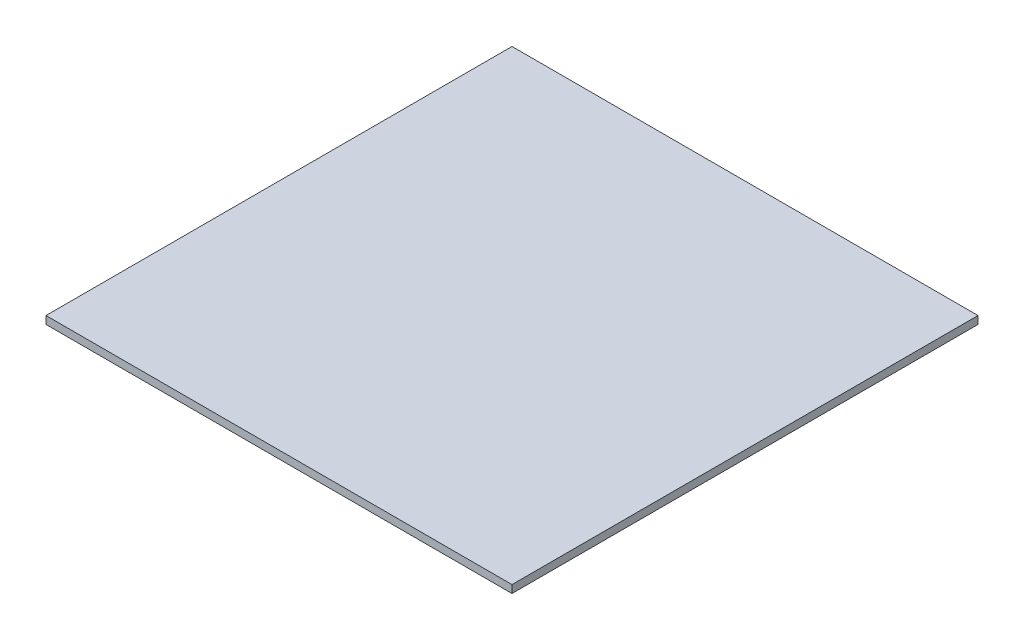
from build123d import *

# Parameters (mm, degrees)
SKETCH1_W           = 609.6
SKETCH1_H           = 609.6
BOSS_EXTRUDE1_DEPTH = 10.16


with BuildPart() as part:
    # Sketch1 → Boss-Extrude1 (new body)
    with BuildSketch(Plane(origin=(0, 0, 0), x_dir=(1, 0, 0), z_dir=(0, 1, 0))):
        with Locations((304.8, 304.8)):
            Rectangle(SKETCH1_W, SKETCH1_H)
    extrude(amount=BOSS_EXTRUDE1_DEPTH)


solid = part.part
